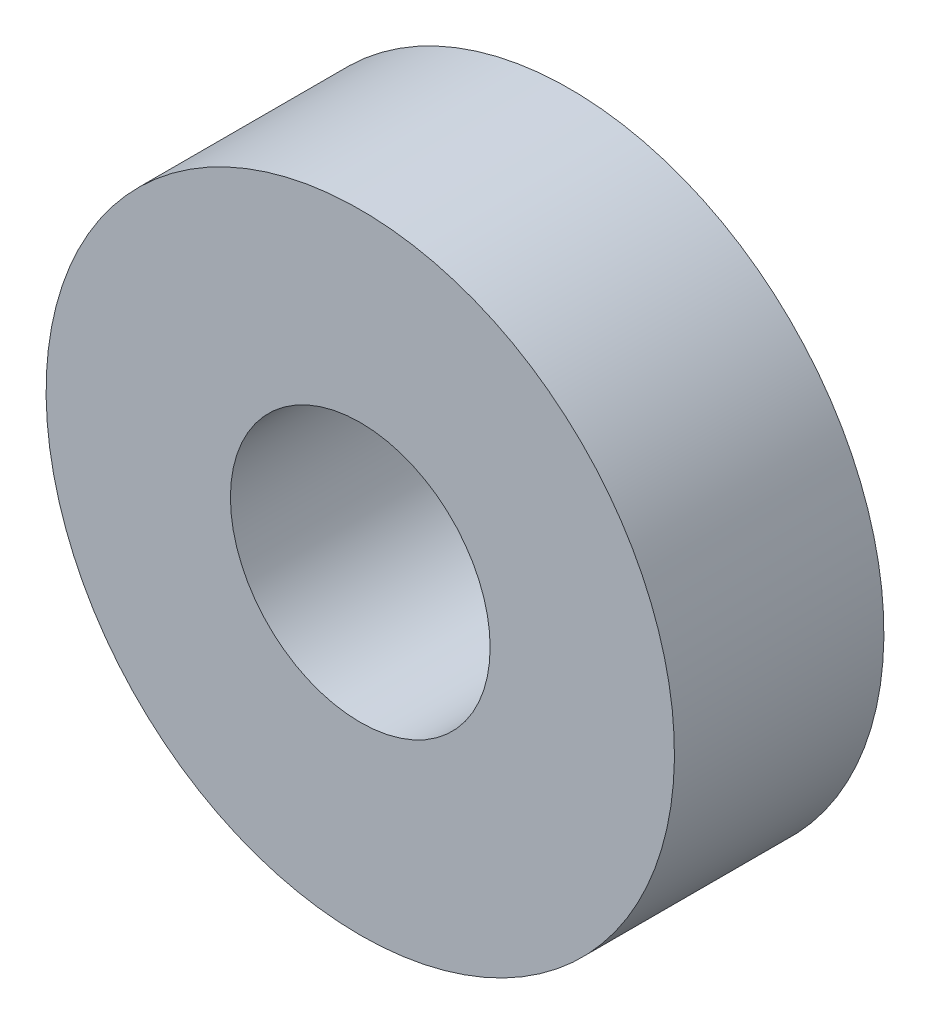
from build123d import *

# Parameters (mm, degrees)
SKETCH1_R           = 7.5
SKETCH1_R_2         = 3
BOSS_EXTRUDE1_DEPTH = 3.82499
SKETCH2_R           = 7.5
SKETCH2_R_2         = 3
BOSS_EXTRUDE2_DEPTH = 1.17501
CUT_EXTRUDE1_REACH  = 7
SKETCH3_R           = 3.1


with BuildPart() as part:
    # Sketch1 → Boss-Extrude1 (new body)
    with BuildSketch(Plane.XY.offset(12.6)):
        with Locations((-69.999984325, 14.142135624)):
            Circle(SKETCH1_R)
        with Locations((-69.999984325, 14.142135624)):
            Circle(SKETCH1_R_2, mode=Mode.SUBTRACT)
    extrude(amount=BOSS_EXTRUDE1_DEPTH)

    # Sketch2 → Boss-Extrude2 (add)
    with BuildSketch(Plane(origin=(0, 0, 12.6), x_dir=(-1, 0, 0), z_dir=(0, 0, -1))):
        with Locations((69.999984325, 14.142135624)):
            Circle(SKETCH2_R)
        with Locations((69.999984325, 14.142135624)):
            Circle(SKETCH2_R_2, mode=Mode.SUBTRACT)
    extrude(amount=BOSS_EXTRUDE2_DEPTH)

    # Sketch3 → Cut-Extrude1 (cut, up to next)
    with BuildSketch(Plane(origin=(0, 0, 11.424990227), x_dir=(-1, 0, 0), z_dir=(0, 0, -1)), mode=Mode.PRIVATE) as cut_extrude1_sk1:
        with Locations((69.999984325, 14.142135624)):
            Circle(SKETCH3_R)
    cut_extrude1_tool1 = extrude(cut_extrude1_sk1.sketch, amount=-CUT_EXTRUDE1_REACH, mode=Mode.PRIVATE) & part.part
    add(cut_extrude1_tool1.solids().sort_by_distance((-69.999984, 14.142136, 11.42499))[0], mode=Mode.SUBTRACT)


solid = part.part
